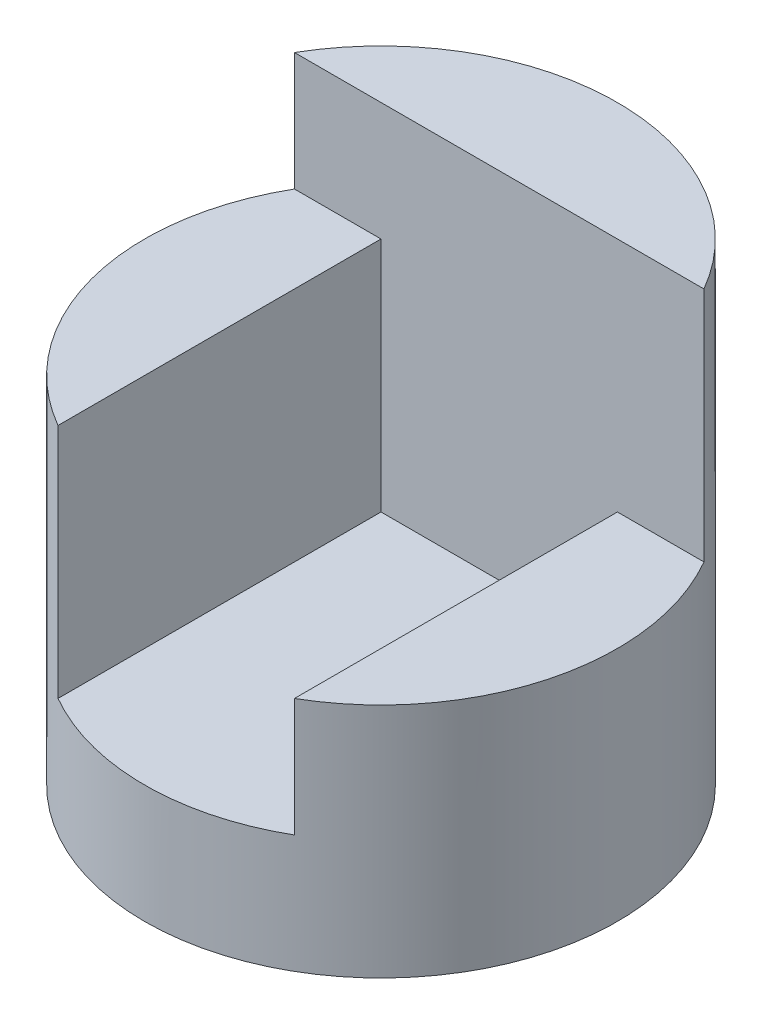
from build123d import *

# Parameters (mm, degrees)
SKETCH1_R               = 2
BOSS_EXTRUDE1_DEPTH     = 4
CUT_EXTRUDE1_DEPTH      = 3
CUT_EXTRUDE1_DEPTH_BACK = 1
SKETCH3_W               = 1
SKETCH3_H               = 1
CUT_EXTRUDE2_DEPTH      = 10


with BuildPart() as part:
    # Sketch1 → Boss-Extrude1 (new body)
    with BuildSketch(Plane(origin=(0, 0, 0), x_dir=(1, 0, 0), z_dir=(0, 1, 0))):
        Circle(SKETCH1_R)
    extrude(amount=BOSS_EXTRUDE1_DEPTH)

    # Sketch2 → Cut-Extrude1 (cut, two sides)
    with BuildSketch(Plane.XY) as cut_extrude1_sk:
        Polygon((-2, 4), (2, 4), (2, 3), (1, 3), (1, 1), (-1, 1), (-1, 3), (-2, 3), align=None)
    extrude(amount=CUT_EXTRUDE1_DEPTH, mode=Mode.SUBTRACT)
    extrude(cut_extrude1_sk.sketch, amount=-CUT_EXTRUDE1_DEPTH_BACK, mode=Mode.SUBTRACT)

    # Sketch3 → Cut-Extrude2 (cut)
    with BuildSketch(Plane.XY.offset(-1)):
        with Locations((1.5, 2.5)):
            Rectangle(SKETCH3_W, SKETCH3_H)
    extrude(amount=CUT_EXTRUDE2_DEPTH, mode=Mode.SUBTRACT)


solid = part.part
